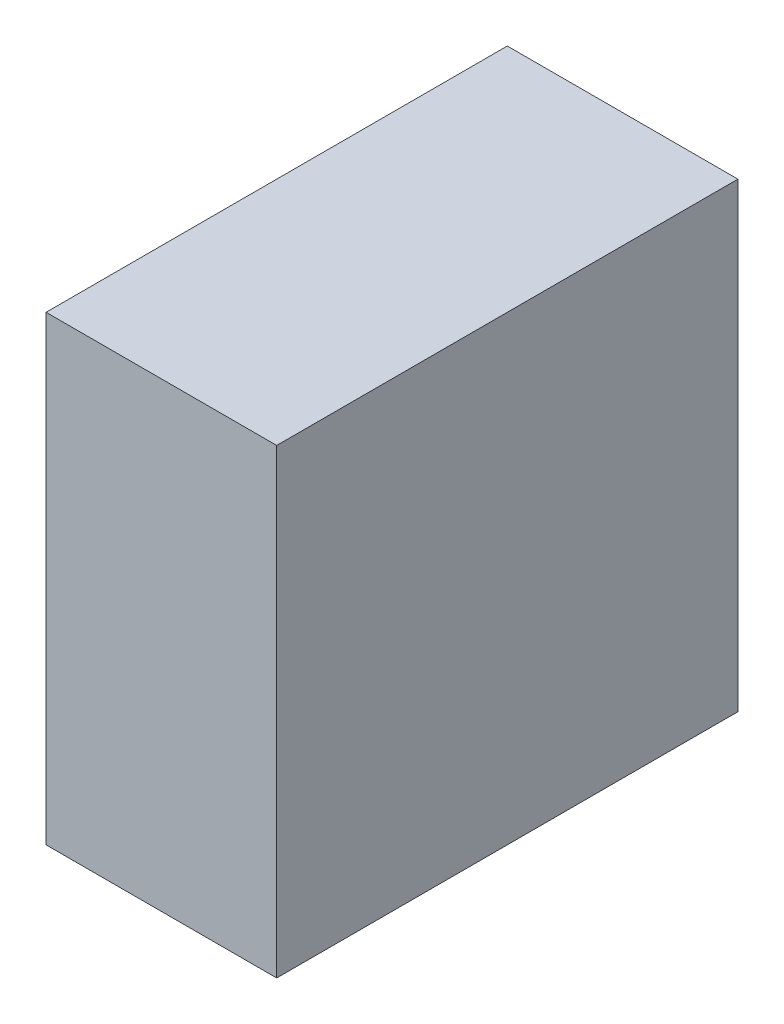
from build123d import *

# Parameters (mm, degrees)
SKETCH1_W           = 25.4
SKETCH1_H           = 50.8
BOSS_EXTRUDE1_DEPTH = 50.8


with BuildPart() as part:
    # Sketch1 → Boss-Extrude1 (new body)
    with BuildSketch(Plane(origin=(0, 0, 0), x_dir=(1, 0, 0), z_dir=(0, 1, 0))):
        with Locations((-6.147245509, -3.326649403)):
            Rectangle(SKETCH1_W, SKETCH1_H)
    extrude(amount=BOSS_EXTRUDE1_DEPTH)


solid = part.part
